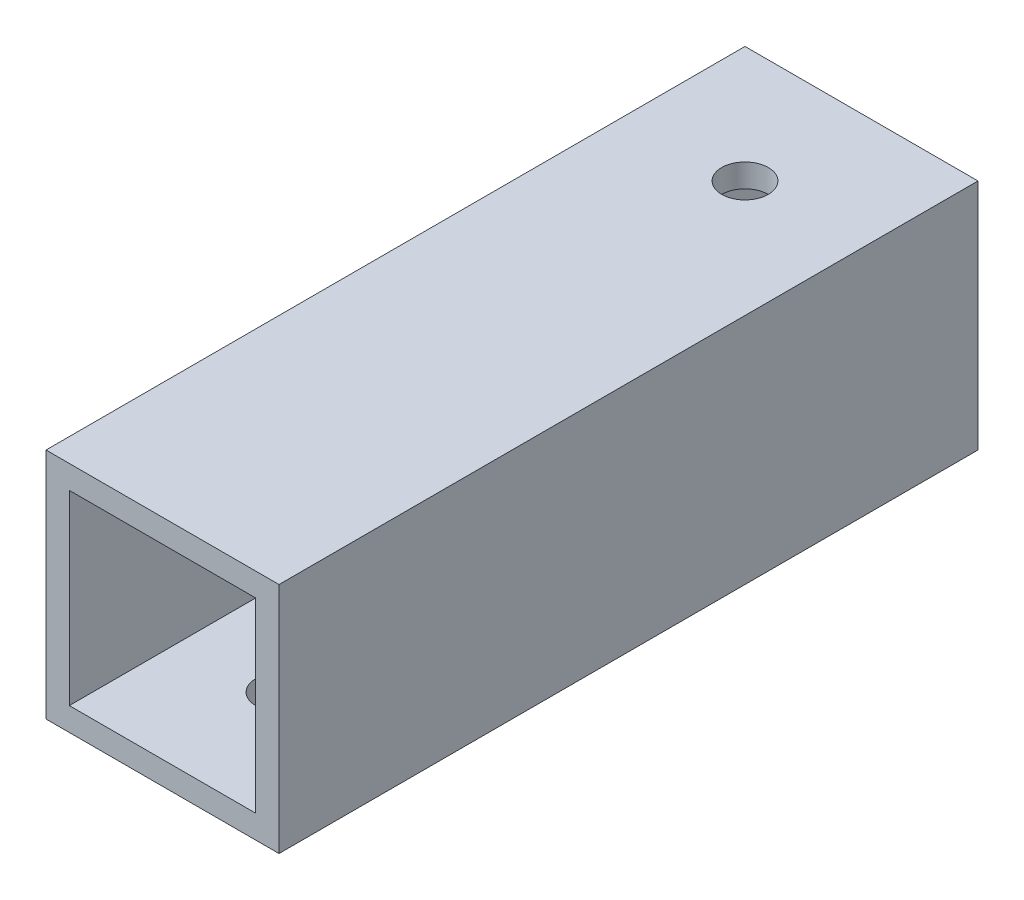
from build123d import *

# Parameters (mm, degrees)
SKETCH_1_W          = 15
SKETCH_1_H          = 15
SKETCH_1_W_2        = 12
SKETCH_1_H_2        = 12
EXTRUDE_2_DEPTH     = 45
SKETCH_2_R          = 1.5
CUT_EXTRUDE_1_DEPTH = 10
SKETCH_3_R          = 1.5
CUT_EXTRUDE_2_DEPTH = 10
SKETCH_7_R          = 1
CUT_EXTRUDE_5_DEPTH = 10


with BuildPart() as part:
    # ｽｹｯﾁ1 → ﾎﾞｽ - 押し出し2 (new body)
    with BuildSketch(Plane.XY):
        with Locations((0.489915859, 0.232626086)):
            Rectangle(SKETCH_1_W, SKETCH_1_H)
        with Locations((0.489915859, 0.232626086)):
            Rectangle(SKETCH_1_W_2, SKETCH_1_H_2, mode=Mode.SUBTRACT)
    extrude(amount=EXTRUDE_2_DEPTH)

    # ｽｹｯﾁ2 → ｶｯﾄ - 押し出し1 (cut)
    with BuildSketch(Plane(origin=(0, 7.732626086, 0), x_dir=(1, 0, 0), z_dir=(0, 1, 0))):
        with Locations((0.489915859, -7.5)):
            Circle(SKETCH_2_R)
    extrude(amount=-CUT_EXTRUDE_1_DEPTH, mode=Mode.SUBTRACT)

    # ｽｹｯﾁ3 → ｶｯﾄ - 押し出し2 (cut)
    with BuildSketch(Plane.XZ.offset(7.267373914)):
        with Locations((0.489915859, 37.5)):
            Circle(SKETCH_3_R)
    extrude(amount=-CUT_EXTRUDE_2_DEPTH, mode=Mode.SUBTRACT)

    # ｽｹｯﾁ7 → ｶｯﾄ - 押し出し5 (cut)
    with BuildSketch(Plane.ZY.offset(7.010084141)):
        with Locations((25.6, -2.967373914)):
            Circle(SKETCH_7_R)
        with Locations((14.8, -2.967373914)):
            Circle(SKETCH_7_R)
    extrude(amount=-CUT_EXTRUDE_5_DEPTH, mode=Mode.SUBTRACT)


solid = part.part
